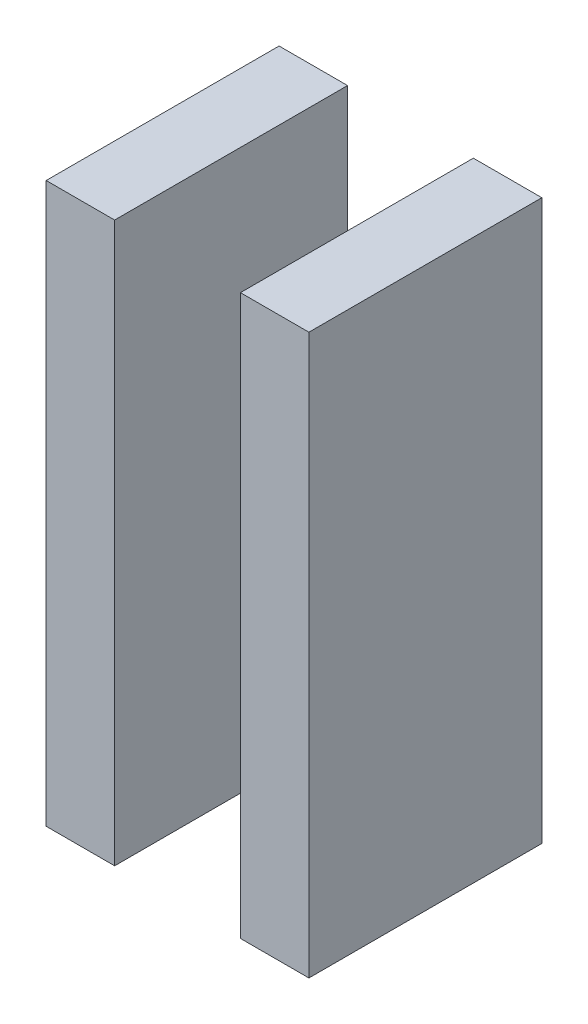
from build123d import *

# Parameters (mm, degrees)
SKIZZE1_W                         = 2.94
SKIZZE1_H                         = 24.01
AUFSATZ_LINEAR_AUSTRAGEN1_DEPTH   = 10
AUFSATZ_LINEAR_AUSTRAGEN1_2_DEPTH = 10


with BuildPart() as part:
    # Skizze1 → Aufsatz-Linear austragen1 (new body)
    with BuildSketch(Plane.XY):
        with Locations((193.5, -46.1)):
            Rectangle(SKIZZE1_W, SKIZZE1_H)
    extrude(amount=AUFSATZ_LINEAR_AUSTRAGEN1_DEPTH)


with BuildPart() as body_2:
    # Skizze1 → Aufsatz-Linear austragen1 2 (new body)
    with BuildSketch(Plane.XY):
        with Locations((201.84, -46.1)):
            Rectangle(SKIZZE1_W, SKIZZE1_H)
    extrude(amount=AUFSATZ_LINEAR_AUSTRAGEN1_2_DEPTH)


solid = Compound([part.part, body_2.part])
